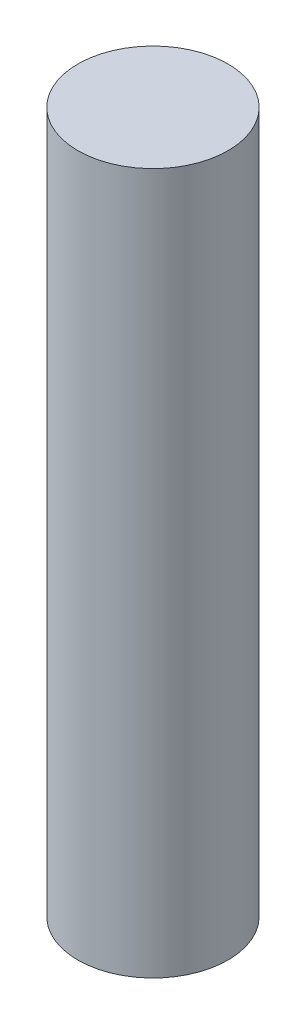
from build123d import *

# Parameters (mm, degrees)
SKETCH1_R           = 9.525
BOSS_EXTRUDE1_DEPTH = 88.9


with BuildPart() as part:
    # Sketch1 → Boss-Extrude1 (new body)
    with BuildSketch(Plane(origin=(0, 0, 0), x_dir=(1, 0, 0), z_dir=(0, 1, 0))):
        Circle(SKETCH1_R)
    extrude(amount=BOSS_EXTRUDE1_DEPTH)


solid = part.part
